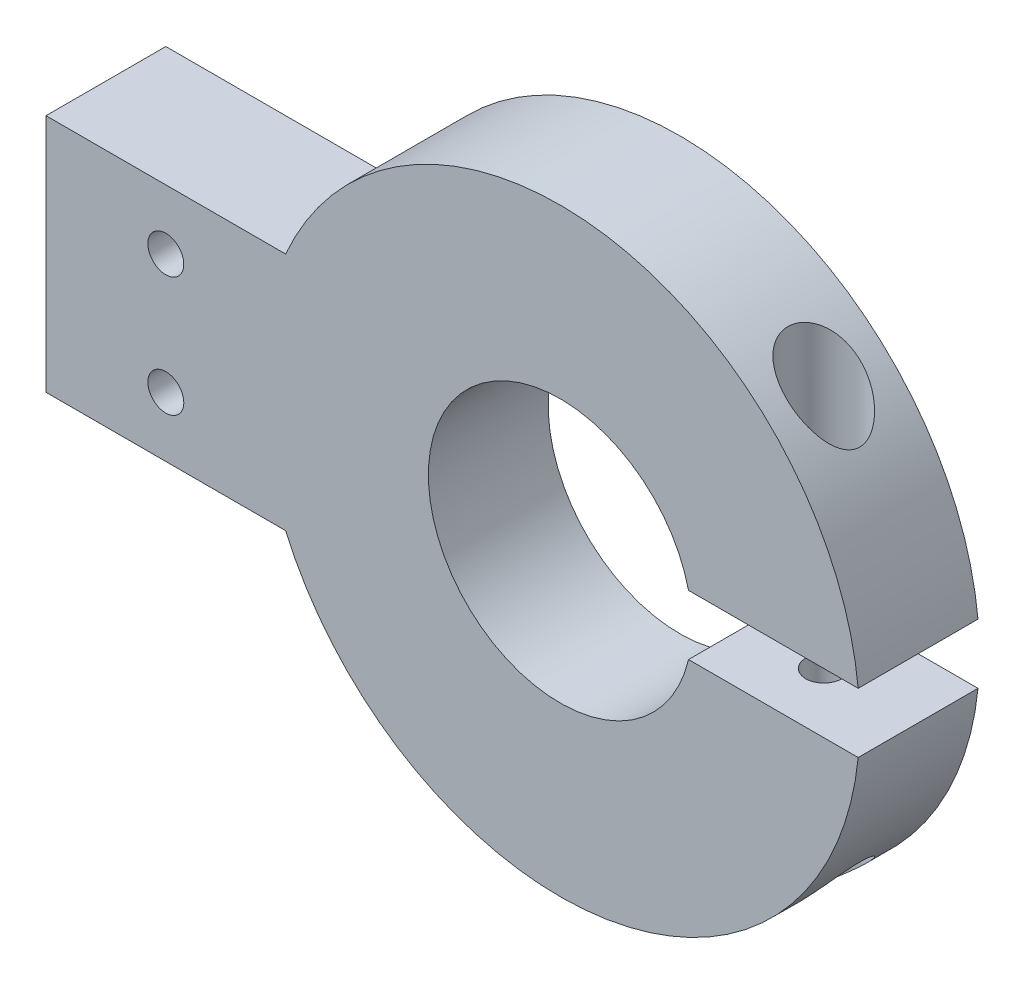
from build123d import *

# Parameters (mm, degrees)
SKETCH1_R               = 25
SKETCH1_R_2             = 11
BOSS_EXTRUDE1_DEPTH     = 10
CUT_EXTRUDE1_DEPTH      = 10
CUT_EXTRUDE4_DEPTH      = 39.487010796
CUT_EXTRUDE4_DEPTH_BACK = 39.487010796
SKETCH5_R               = 1.5
CUT_EXTRUDE5_START      = 30
SKETCH6_R               = 3
CUT_EXTRUDE5_DEPTH      = 20
CUT_EXTRUDE6_START      = -30
CUT_EXTRUDE6_DEPTH      = 25
CUT_EXTRUDE8_START      = 5
SKETCH8_R               = 3
CUT_EXTRUDE8_DEPTH      = 15
SKETCH9_W               = 20
SKETCH9_H               = 19.995459106
SKETCH9_R               = 1.5
BOSS_EXTRUDE2_DEPTH     = 10


with BuildPart() as part:
    # Sketch1 → Boss-Extrude1 (new body)
    with BuildSketch(Plane.XY):
        Circle(SKETCH1_R)
        Circle(SKETCH1_R_2, mode=Mode.SUBTRACT)
    extrude(amount=BOSS_EXTRUDE1_DEPTH)

    # Sketch2 → Cut-Extrude1 (cut)
    with BuildSketch(Plane.XY.offset(10)):
        Polygon((25, 0), (25, 2.5), (0, 2.5), (0, 0), (0, -2.5), (25, -2.5), align=None)
    extrude(amount=-CUT_EXTRUDE1_DEPTH, mode=Mode.SUBTRACT)

    # Sketch5 → Cut-Extrude4 (cut, two sides: drawn at the far end of the back side and taken through both)
    with BuildSketch(Plane(origin=(0, -2.5, 0), x_dir=(1, 0, 0), z_dir=(0, 1, 0)).offset(-CUT_EXTRUDE4_DEPTH_BACK)):
        with Locations((17, -5)):
            Circle(SKETCH5_R)
    extrude(amount=CUT_EXTRUDE4_DEPTH + CUT_EXTRUDE4_DEPTH_BACK, mode=Mode.SUBTRACT)

    # Sketch6 → Cut-Extrude5 (cut)
    with BuildSketch(Plane(origin=(0, -2.5, 0), x_dir=(1, 0, 0), z_dir=(0, 1, 0)).offset(CUT_EXTRUDE5_START)):
        with Locations((17, -5)):
            Circle(SKETCH6_R)
    extrude(amount=-CUT_EXTRUDE5_DEPTH, mode=Mode.SUBTRACT)

    # Sketch7 → Cut-Extrude6 (cut)
    with BuildSketch(Plane(origin=(0, -2.5, 0), x_dir=(1, 0, 0), z_dir=(0, 1, 0)).offset(CUT_EXTRUDE6_START)):
        Polygon((19.309401077, -5), (18.154700538, -3), (15.845299462, -3), (14.690598923, -5), (15.845299462, -7), (18.154700538, -7), align=None)
    extrude(amount=CUT_EXTRUDE6_DEPTH, mode=Mode.SUBTRACT)

    # Sketch8 → Cut-Extrude8 (cut)
    with BuildSketch(Plane.XZ.offset(7.5).offset(CUT_EXTRUDE8_START)):
        with Locations((17, 5)):
            Circle(SKETCH8_R)
    extrude(amount=CUT_EXTRUDE8_DEPTH, mode=Mode.SUBTRACT)

    # Sketch9 → Boss-Extrude2 (add)
    with BuildSketch(Plane(origin=(0, 0, 0), x_dir=(-1, 0, 0), z_dir=(0, 0, -1))):
        with Locations((32.913869245, 0)):
            Rectangle(SKETCH9_W, SKETCH9_H)
        with Locations((32.913869245, 5)):
            Circle(SKETCH9_R, mode=Mode.SUBTRACT)
        with Locations((32.913869245, -5)):
            Circle(SKETCH9_R, mode=Mode.SUBTRACT)
    extrude(amount=-BOSS_EXTRUDE2_DEPTH)


solid = part.part
